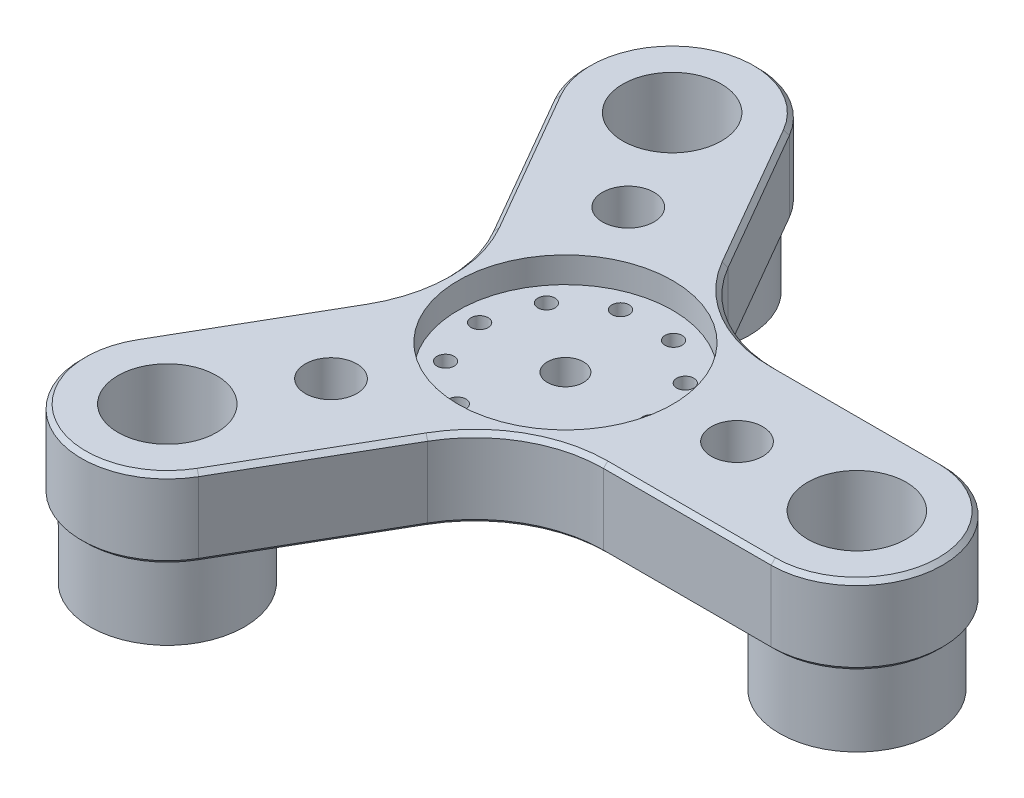
from build123d import *

# Parameters (mm, degrees)
SKETCH_1_R          = 5.75
EXTRUDE_1_DEPTH     = 9.25
FILLET_1_R          = 15
SKETCH_2_R          = 12.5
CUT_EXTRUDE_1_DEPTH = 3
SKETCH_3_R          = 2.1
CUT_EXTRUDE_2_DEPTH = 7.25
SKETCH_4_R          = 1
CUT_EXTRUDE_3_DEPTH = 7.25
SKETCH_5_R          = 9
SKETCH_5_R_2        = 5.75
EXTRUDE_2_DEPTH     = 8.75
SKETCH_6_R          = 4.71
SKETCH_6_R_2        = 2.1
EXTRUDE_3_DEPTH     = 2.5
CHAMFER_1_SIZE      = 0.5
CHAMFER_2_SIZE      = 0.5
SKETCH_7_R          = 3
CUT_EXTRUDE_4_DEPTH = 19


with BuildPart() as part:
    # ｽｹｯﾁ1 → ﾎﾞｽ - 押し出し1 (new body)
    with BuildSketch(Plane(origin=(0, 0, 0), x_dir=(1, 0, 0), z_dir=(0, 1, 0))):
        with BuildLine():
            Line((-8.324355962, -34.418207467), (5.773502692, -10))
            Line((5.773502692, -10), (33.96922, -10))
            ThreePointArc((33.96922, -10), (43.96922, 0), (33.96922, 10))
            Line((33.96922, 10), (5.773502692, 10))
            Line((5.773502692, 10), (-8.324355962, 34.418207467))
            ThreePointArc((-8.324355962, 34.418207467), (-21.98461, 38.078461505), (-25.644864038, 24.418207467))
            Line((-25.644864038, 24.418207467), (-11.547005384, 0))
            Line((-11.547005384, 0), (-25.644864038, -24.418207467))
            ThreePointArc((-25.644864038, -24.418207467), (-21.98461, -38.078461505), (-8.324355962, -34.418207467))
        make_face()
        with Locations((-16.98461, 29.418207467)):
            Circle(SKETCH_1_R, mode=Mode.SUBTRACT)
        with Locations((-16.98461, -29.418207467)):
            Circle(SKETCH_1_R, mode=Mode.SUBTRACT)
        with Locations((33.96922, 0)):
            Circle(SKETCH_1_R, mode=Mode.SUBTRACT)
    extrude(amount=EXTRUDE_1_DEPTH)

    # ﾌｨﾚｯﾄ1
    fillet_1_edges = [part.edges().sort_by_distance(p)[0] for p in [
        (5.773502692, 4.625, 10),
        (-11.547005384, 4.625, 0),
        (5.773502692, 4.625, -10),
    ]]
    fillet(fillet_1_edges, radius=FILLET_1_R)

    # ｽｹｯﾁ2 → ｶｯﾄ - 押し出し1 (cut)
    with BuildSketch(Plane(origin=(0, 9.25, 0), x_dir=(1, 0, 0), z_dir=(0, 1, 0))):
        Circle(SKETCH_2_R)
    extrude(amount=-CUT_EXTRUDE_1_DEPTH, mode=Mode.SUBTRACT)

    # ｽｹｯﾁ3 → ｶｯﾄ - 押し出し2 (cut, through all)
    with BuildSketch(Plane(origin=(0, 6.25, 0), x_dir=(1, 0, 0), z_dir=(0, 1, 0))):
        Circle(SKETCH_3_R)
    extrude(amount=-CUT_EXTRUDE_2_DEPTH, mode=Mode.SUBTRACT)

    # ｽｹｯﾁ4 → ｶｯﾄ - 押し出し3 (cut, through all)
    with BuildSketch(Plane(origin=(0, 6.25, 0), x_dir=(1, 0, 0), z_dir=(0, 1, 0))):
        with Locations((10, 0)):
            Circle(SKETCH_4_R)
        with Locations((8.090169944, -5.877852523)):
            Circle(SKETCH_4_R)
        with Locations((3.090169944, -9.510565163)):
            Circle(SKETCH_4_R)
        with Locations((-3.090169944, -9.510565163)):
            Circle(SKETCH_4_R)
        with Locations((-8.090169944, -5.877852523)):
            Circle(SKETCH_4_R)
        with Locations((-10, 0)):
            Circle(SKETCH_4_R)
        with Locations((-8.090169944, 5.877852523)):
            Circle(SKETCH_4_R)
        with Locations((-3.090169944, 9.510565163)):
            Circle(SKETCH_4_R)
        with Locations((3.090169944, 9.510565163)):
            Circle(SKETCH_4_R)
        with Locations((8.090169944, 5.877852523)):
            Circle(SKETCH_4_R)
    extrude(amount=-CUT_EXTRUDE_3_DEPTH, mode=Mode.SUBTRACT)

    # ｽｹｯﾁ5 → ﾎﾞｽ - 押し出し2 (add)
    with BuildSketch(Plane.XZ):
        with Locations((-16.98461, -29.418207467)):
            Circle(SKETCH_5_R)
        with Locations((-16.98461, -29.418207467)):
            Circle(SKETCH_5_R_2, mode=Mode.SUBTRACT)
        with Locations((-16.98461, 29.418207467)):
            Circle(SKETCH_5_R)
        with Locations((-16.98461, 29.418207467)):
            Circle(SKETCH_5_R_2, mode=Mode.SUBTRACT)
        with Locations((33.96922, 0)):
            Circle(SKETCH_5_R)
        with Locations((33.96922, 0)):
            Circle(SKETCH_5_R_2, mode=Mode.SUBTRACT)
    extrude(amount=EXTRUDE_2_DEPTH)

    # ｽｹｯﾁ6 → ﾎﾞｽ - 押し出し3 (add)
    with BuildSketch(Plane.XZ):
        Circle(SKETCH_6_R)
        Circle(SKETCH_6_R_2, mode=Mode.SUBTRACT)
    extrude(amount=EXTRUDE_3_DEPTH)

    # 面取り1
    chamfer_1_edges = [part.edges().sort_by_distance(p)[0] for p in [
        (-20.76099822, 0, -15.959103733),
        (-21.98461, 0, -38.078461505),
        (24.201488365, 0, -10),
        (43.96922, 0, 0),
        (-20.76099822, 0, 15.959103733),
        (-3.440490145, 0, -25.959103733),
        (24.201488365, 0, 10),
        (-13.867513459, 0, 0),
        (6.93375673, 0, -12.009618943),
        (6.93375673, 0, 12.009618943),
        (-3.440490145, 0, 25.959103733),
        (-21.98461, 0, 38.078461505),
    ]]
    chamfer(chamfer_1_edges, length=CHAMFER_1_SIZE)

    # 面取り2
    chamfer_2_edges = [part.edges().sort_by_distance(p)[0] for p in [
        (-21.98461, 9.25, -38.078461505),
        (-20.76099822, 9.25, -15.959103733),
        (-21.98461, 9.25, 38.078461505),
        (-3.440490145, 9.25, 25.959103733),
        (-20.76099822, 9.25, 15.959103733),
        (43.96922, 9.25, 0),
        (-3.440490145, 9.25, -25.959103733),
        (24.201488365, 9.25, 10),
        (-13.867513459, 9.25, 0),
        (6.93375673, 9.25, -12.009618943),
        (6.93375673, 9.25, 12.009618943),
        (24.201488365, 9.25, -10),
    ]]
    chamfer(chamfer_2_edges, length=CHAMFER_2_SIZE)

    # ｽｹｯﾁ7 → ｶｯﾄ - 押し出し4 (cut, through all)
    with BuildSketch(Plane(origin=(0, 9.25, 0), x_dir=(1, 0, 0), z_dir=(0, 1, 0))):
        with Locations((20, 0)):
            Circle(SKETCH_7_R)
        with Locations((-10, -17.320508076)):
            Circle(SKETCH_7_R)
        with Locations((-10, 17.320508076)):
            Circle(SKETCH_7_R)
    extrude(amount=-CUT_EXTRUDE_4_DEPTH, mode=Mode.SUBTRACT)


solid = part.part
